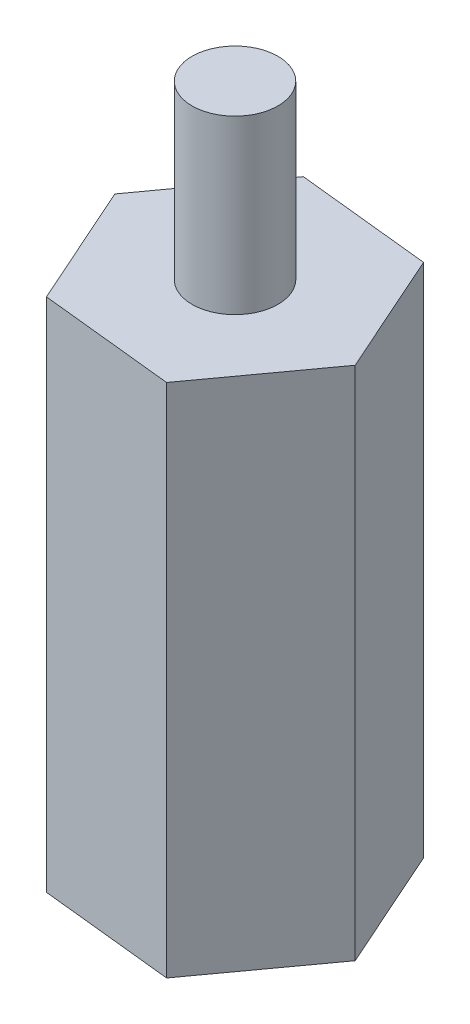
from build123d import *

# Parameters (mm, degrees)
SKETCH1_R           = 1.25
BOSS_EXTRUDE1_DEPTH = 15
SKETCH2_R           = 1.25
BOSS_EXTRUDE2_DEPTH = 5


with BuildPart() as part:
    # Sketch1 → Boss-Extrude1 (new body)
    with BuildSketch(Plane(origin=(0, 0, 0), x_dir=(1, 0, 0), z_dir=(0, 1, 0))):
        Polygon((2.307316277, 3.176622058), (-1.597377262, 3.586505539), (-3.904693539, 0.409883482), (-2.307316277, -3.176622058), (1.597377262, -3.586505539), (3.904693539, -0.409883482), align=None)
        Circle(SKETCH1_R, mode=Mode.SUBTRACT)
    extrude(amount=BOSS_EXTRUDE1_DEPTH)


with BuildPart() as body_2:
    # Sketch2 → Boss-Extrude2 (new body)
    with BuildSketch(Plane(origin=(0, 15, 0), x_dir=(1, 0, 0), z_dir=(0, 1, 0))):
        Circle(SKETCH2_R)
    extrude(amount=BOSS_EXTRUDE2_DEPTH)


solid = Compound([part.part, body_2.part])
